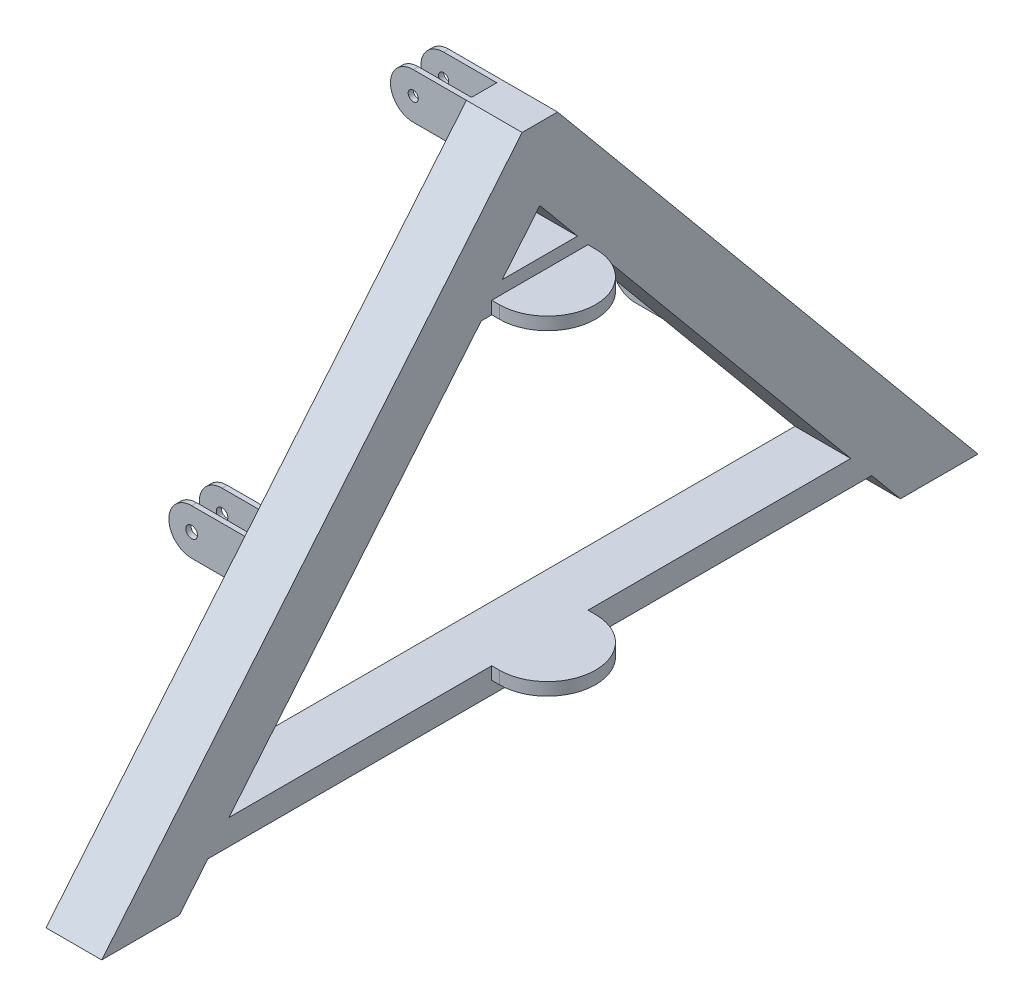
from build123d import *

# Parameters (mm, degrees)
BOSS_EXTRUDE1_DEPTH     = 100
BOSS_EXTRUDE1_2_DEPTH   = 100
BOSS_EXTRUDE1_3_DEPTH   = 100
SKETCH2_W               = 10
SKETCH2_H               = 90
BOSS_EXTRUDE2_DEPTH     = 150
BOSS_EXTRUDE3_DEPTH     = 10
SKETCH4_R               = 11.5
SKETCH4_R_2             = 10
CUT_EXTRUDE2_DEPTH      = 393.670777989
CUT_EXTRUDE2_DEPTH_BACK = 1338.670777989
BOSS_EXTRUDE4_DEPTH     = 100
BOSS_EXTRUDE5_DEPTH     = 10
SKETCH11_W              = 190
SKETCH11_H              = 25
BOSS_EXTRUDE7_DEPTH     = 110
BOSS_EXTRUDE7_2_DEPTH   = 110
BOSS_EXTRUDE11_DEPTH    = 110
CUT_EXTRUDE4_DEPTH      = 744.062857143
CUT_EXTRUDE5_START      = -55
CUT_EXTRUDE5_DEPTH      = 45


with BuildPart() as part:
    # Sketch1 → Boss-Extrude1 (new body)
    with BuildSketch(Plane(origin=(0, 0, 0), x_dir=(0, 0, -1), z_dir=(1, 0, 0))):
        Polygon((-462.5, 0), (-412.5, 0), (-412.5, -80), (-402.5, -80), (-402.5, 0), (-327.5, 0), (-327.5, 10), (-472.5, 10), (-472.5, -80), (-462.5, -80), align=None)
    extrude(amount=BOSS_EXTRUDE1_DEPTH)



with BuildPart() as body_2:
    # Sketch1 → Boss-Extrude1 2 (new body)
    with BuildSketch(Plane(origin=(0, 0, 0), x_dir=(0, 0, -1), z_dir=(1, 0, 0))):
        Polygon((25, 457), (-25, 457), (-25, 537), (-35, 537), (-35, 457), (-101.413662239, 457), (-101.413662239, 447), (101.413662239, 447), (101.413662239, 457), (35, 457), (35, 537), (25, 537), align=None)
    extrude(amount=BOSS_EXTRUDE1_2_DEPTH)


with BuildPart() as body_3:
    # Sketch1 → Boss-Extrude1 3 (new body)
    with BuildSketch(Plane(origin=(0, 0, 0), x_dir=(0, 0, -1), z_dir=(1, 0, 0))):
        Polygon((402.5, 0), (327.5, 0), (327.5, 10), (472.5, 10), (472.5, -80), (462.5, -80), (462.5, 0), (412.5, 0), (412.5, -80), (402.5, -80), align=None)
    extrude(amount=BOSS_EXTRUDE1_3_DEPTH)


with BuildPart() as part_1:
    add(part.part)

    add(body_2.part)  # Boss-Extrude2 merges body 2

    add(body_3.part)  # Boss-Extrude2 merges body 3
    # Sketch2 → Boss-Extrude2 (add)
    with BuildSketch(Plane.ZY):
        with Locations((-467.5, -35)):
            Rectangle(SKETCH2_W, SKETCH2_H)
        with Locations((-407.5, -35)):
            Rectangle(SKETCH2_W, SKETCH2_H)
        with Locations((-30, 492)):
            Rectangle(SKETCH2_W, SKETCH2_H)
        with Locations((30, 492)):
            Rectangle(SKETCH2_W, SKETCH2_H)
        with Locations((407.5, -35)):
            Rectangle(SKETCH2_W, SKETCH2_H)
        with Locations((467.5, -35)):
            Rectangle(SKETCH2_W, SKETCH2_H)
    extrude(amount=BOSS_EXTRUDE2_DEPTH)

    # Sketch3 → Boss-Extrude3 (add)
    with BuildSketch(Plane(origin=(100, 0, 0), x_dir=(0, 0, -1), z_dir=(1, 0, 0))):
        Polygon((-472.5, 10), (-35, 537), (35, 537), (472.5, 10), (865.170777989, -463), (711.869070209, -463), (327.5, 0), (0, 394.497142857), (-327.5, 0), (-711.869070209, -463), (-865.170777989, -463), align=None)
    extrude(amount=BOSS_EXTRUDE3_DEPTH)

    # Sketch4 → Cut-Extrude2 (cut, two sides)
    with BuildSketch(Plane.XY.offset(472.5)) as cut_extrude2_sk:
        with BuildLine():
            ThreePointArc((-150, -34.999999852), (-136.819805101, -3.180194794), (-105, 10))
            Line((-105, 10), (-150, 10))
            Line((-150, 10), (-150, -34.999999852))
        make_face()
        with Locations((-105, -35)):
            Circle(SKETCH4_R)
        with BuildLine():
            ThreePointArc((-105, -80), (-136.819805188, -66.819805118), (-150, -34.999999901))
            Line((-150, -34.999999901), (-150, -80))
            Line((-150, -80), (-105, -80))
        make_face()
        with Locations((-105, 492)):
            Circle(SKETCH4_R_2)
        with BuildLine():
            Line((-150, 537), (-150, 492))
            ThreePointArc((-150, 492), (-136.819805153, 523.819805153), (-105, 537))
            Line((-105, 537), (-150, 537))
        make_face()
        with BuildLine():
            Line((-150, 447), (-105, 447))
            ThreePointArc((-105, 447), (-136.819805153, 460.180194847), (-150, 492))
            Line((-150, 492), (-150, 447))
        make_face()
    extrude(amount=CUT_EXTRUDE2_DEPTH, mode=Mode.SUBTRACT)
    extrude(cut_extrude2_sk.sketch, amount=-CUT_EXTRUDE2_DEPTH_BACK, mode=Mode.SUBTRACT)

    # Sketch5 → Boss-Extrude4 (add)
    with BuildSketch(Plane.ZY.offset(-100)):
        Polygon((-865.170777989, -463), (-35, 537), (35, 537), (865.170777989, -463), (711.869070209, -463), (0, 394.497142857), (-711.869070209, -463), align=None)
        Polygon((-843.872210893, -453), (-716.564221744, -453), (0, 410.15278825), (716.564221744, -453), (843.872210893, -453), (30.304848465, 527), (-30.304848465, 527), align=None, mode=Mode.SUBTRACT)
    extrude(amount=BOSS_EXTRUDE4_DEPTH)

    # Sketch8 → Boss-Extrude5 (add)
    with BuildSketch(Plane.ZY):
        Polygon((-472.5, 10), (-865.170777989, -463), (-711.869070209, -463), (0, 394.497142857), (711.869070209, -463), (865.170777989, -463), (472.5, 10), (35, 537), (-35, 537), align=None)
    extrude(amount=-BOSS_EXTRUDE5_DEPTH)



with BuildPart() as body_2_2:
    # Sketch11 → Boss-Extrude7 (new body, symmetric)
    with BuildSketch(Plane(origin=(110, 0, 0), x_dir=(0, 0, -1), z_dir=(1, 0, 0))):
        with Locations((0, 267.562857143)):
            Rectangle(SKETCH11_W, SKETCH11_H)
    extrude(amount=BOSS_EXTRUDE7_DEPTH, both=True)


with BuildPart() as body_3_2:
    # Sketch11 → Boss-Extrude7 2 (new body, symmetric)
    with BuildSketch(Plane(origin=(110, 0, 0), x_dir=(0, 0, -1), z_dir=(1, 0, 0))):
        with Locations((0, -357.437142857)):
            Rectangle(SKETCH11_W, SKETCH11_H)
    extrude(amount=BOSS_EXTRUDE7_2_DEPTH, both=True)


with BuildPart() as part_2:
    add(part_1.part)

    add(body_2_2.part)  # Boss-Extrude11 merges body 2 2

    add(body_3_2.part)  # Boss-Extrude11 merges body 3 2
    # Sketch13 → Boss-Extrude11 (add)
    with BuildSketch(Plane(origin=(110, 0, 0), x_dir=(0, 0, -1), z_dir=(1, 0, 0))):
        Polygon((74.24573055, 305.062857143), (-74.24573055, 305.062857143), (-115.75426945, 255.062857143), (115.75426945, 255.062857143), align=None)
        Polygon((-613.856736243, -344.937142857), (613.856736243, -344.937142857), (655.365275142, -394.937142857), (-655.365275142, -394.937142857), align=None)
    extrude(amount=-BOSS_EXTRUDE11_DEPTH)

    # Sketch12 → Cut-Extrude4 (cut, through all)
    with BuildSketch(Plane(origin=(0, 280.062857143, 0), x_dir=(1, 0, 0), z_dir=(0, 1, 0))):
        with BuildLine():
            Line((220, 95), (125, 95))
            ThreePointArc((125, 95), (192.175144213, 67.175144213), (220, -1e-09))
            Line((220, -1e-09), (220, 95))
        make_face()
        with BuildLine():
            Line((220, -95), (220, -1e-09))
            ThreePointArc((220, -1e-09), (192.175144213, -67.175144213), (125, -95))
            Line((125, -95), (220, -95))
        make_face()
    extrude(amount=-CUT_EXTRUDE4_DEPTH, mode=Mode.SUBTRACT)

    # Sketch14 → Cut-Extrude5 (cut, symmetric)
    with BuildSketch(Plane.ZY.offset(CUT_EXTRUDE5_START)):
        Polygon((-634.066708047, -384.937142857), (634.066708047, -384.937142857), (609.161584707, -354.937142857), (-609.161584707, -354.937142857), align=None)
        Polygon((-94.455702354, 265.062857143), (94.455702354, 265.062857143), (69.550579015, 295.062857143), (-69.550579015, 295.062857143), align=None)
    extrude(amount=CUT_EXTRUDE5_DEPTH, both=True, mode=Mode.SUBTRACT)


solid = part_2.part
